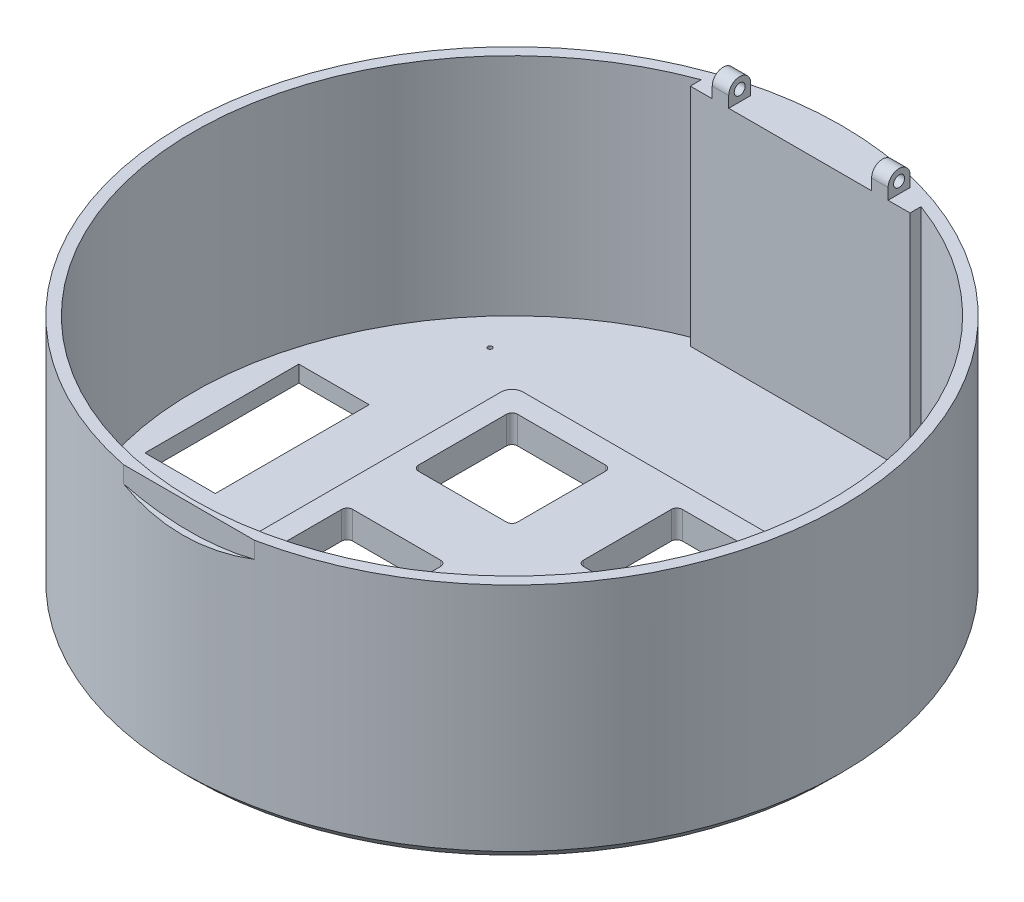
from build123d import *

# Parameters (mm, degrees)
SKETCH1_R                 = 15
BOSS_EXTRUDE1_DEPTH       = 11
SHELL1_T                  = -0.5
SHELL1_THICKNESS_2_FACE_R = 14.5
SHELL1_THICKNESS_2_DEPTH  = 0.25
CUT_EXTRUDE1_REACH        = 25.896
SKETCH2_R                 = 0.1
SKETCH2_W                 = 4.5
SKETCH2_H                 = 4.5
SKETCH2_W_2               = 3.2
SKETCH2_H_2               = 7
CHAMFER1_SIZE             = 0.5
FILLET1_R                 = 0.25
CUT_EXTRUDE2_START        = 15
CUT_EXTRUDE2_DEPTH        = 0.3
BOSS_EXTRUDE2_DEPTH       = 10.25
SKETCH7_W                 = 0.75
SKETCH7_H                 = 1
BOSS_EXTRUDE3_DEPTH       = 1
SKETCH8_R                 = 0.25
CUT_EXTRUDE3_DEPTH        = 28.018512298
BOSS_EXTRUDE5_DEPTH       = 0.5
MIRROR2_COPY_1_DEPTH      = 0.5
SCALE1_SCALE              = 10


with BuildPart() as part:
    # Sketch1 → Boss-Extrude1 (new body)
    with BuildSketch(Plane(origin=(0, 0, 0), x_dir=(1, 0, 0), z_dir=(0, 1, 0))):
        with Locations(Location((0, 0, 0), (0, 0, 270))):
            Circle(SKETCH1_R)
    extrude(amount=BOSS_EXTRUDE1_DEPTH)

    # Shell1
    shell1_openings = [part.faces().sort_by_distance(p)[0] for p in [
        (0, 11, 0),
    ]]
    offset(amount=SHELL1_T, openings=shell1_openings, kind=Kind.INTERSECTION)

    # Shell1 thickness 2 face (on inner face of the shell) → Shell1 thickness 2 (add)
    with BuildSketch(Plane(origin=(0, 0.5, 0), x_dir=(0, 0, -1), z_dir=(0, -1, 0))):
        Circle(SHELL1_THICKNESS_2_FACE_R)
    extrude(amount=-SHELL1_THICKNESS_2_DEPTH)

    # Sketch2 → Cut-Extrude1 (cut, up to next)
    with BuildSketch(Plane.XZ, mode=Mode.PRIVATE) as cut_extrude1_sk1:
        with Locations(Location((-9.5, 8.5, 0), (0, 0, 270))):
            Circle(SKETCH2_R)
    cut_extrude1_tool1 = extrude(cut_extrude1_sk1.sketch, amount=-CUT_EXTRUDE1_REACH, mode=Mode.PRIVATE) & part.part
    # Sketch2 → Cut-Extrude1 (cut, up to next)
    with BuildSketch(Plane.XZ, mode=Mode.PRIVATE) as cut_extrude1_sk2:
        with Locations(Location((-9.5, -8.5, 0), (0, 0, 90))):
            Circle(SKETCH2_R)
    cut_extrude1_tool2 = extrude(cut_extrude1_sk2.sketch, amount=-CUT_EXTRUDE1_REACH, mode=Mode.PRIVATE) & part.part
    # Sketch2 → Cut-Extrude1 (cut, up to next)
    with BuildSketch(Plane.XZ, mode=Mode.PRIVATE) as cut_extrude1_sk3:
        with Locations(Location((9.5, 8.5, 0), (0, 0, 90))):
            Circle(SKETCH2_R)
    cut_extrude1_tool3 = extrude(cut_extrude1_sk3.sketch, amount=-CUT_EXTRUDE1_REACH, mode=Mode.PRIVATE) & part.part
    # Sketch2 → Cut-Extrude1 (cut, up to next)
    with BuildSketch(Plane.XZ, mode=Mode.PRIVATE) as cut_extrude1_sk4:
        with Locations(Location((9.5, -8.5, 0), (0, 0, 270))):
            Circle(SKETCH2_R)
    cut_extrude1_tool4 = extrude(cut_extrude1_sk4.sketch, amount=-CUT_EXTRUDE1_REACH, mode=Mode.PRIVATE) & part.part
    # Sketch2 → Cut-Extrude1 (cut, up to next)
    with BuildSketch(Plane.XZ, mode=Mode.PRIVATE) as cut_extrude1_sk5:
        with Locations((-3.75, 3.75)):
            Rectangle(SKETCH2_W, SKETCH2_H)
    cut_extrude1_tool5 = extrude(cut_extrude1_sk5.sketch, amount=-CUT_EXTRUDE1_REACH, mode=Mode.PRIVATE) & part.part
    # Sketch2 → Cut-Extrude1 (cut, up to next)
    with BuildSketch(Plane.XZ, mode=Mode.PRIVATE) as cut_extrude1_sk6:
        with Locations((-3.75, -3.75)):
            Rectangle(SKETCH2_W, SKETCH2_H)
    cut_extrude1_tool6 = extrude(cut_extrude1_sk6.sketch, amount=-CUT_EXTRUDE1_REACH, mode=Mode.PRIVATE) & part.part
    # Sketch2 → Cut-Extrude1 (cut, up to next)
    with BuildSketch(Plane.XZ, mode=Mode.PRIVATE) as cut_extrude1_sk7:
        with Locations((11.6, 0)):
            Rectangle(SKETCH2_W_2, SKETCH2_H_2)
    cut_extrude1_tool7 = extrude(cut_extrude1_sk7.sketch, amount=-CUT_EXTRUDE1_REACH, mode=Mode.PRIVATE) & part.part
    # Sketch2 → Cut-Extrude1 (cut, up to next)
    with BuildSketch(Plane.XZ, mode=Mode.PRIVATE) as cut_extrude1_sk8:
        with Locations((-11.6, 0)):
            Rectangle(SKETCH2_W_2, SKETCH2_H_2)
    cut_extrude1_tool8 = extrude(cut_extrude1_sk8.sketch, amount=-CUT_EXTRUDE1_REACH, mode=Mode.PRIVATE) & part.part
    # Sketch2 → Cut-Extrude1 (cut, up to next)
    with BuildSketch(Plane.XZ, mode=Mode.PRIVATE) as cut_extrude1_sk9:
        with Locations((3.75, -3.75)):
            Rectangle(SKETCH2_W, SKETCH2_H)
    cut_extrude1_tool9 = extrude(cut_extrude1_sk9.sketch, amount=-CUT_EXTRUDE1_REACH, mode=Mode.PRIVATE) & part.part
    # Sketch2 → Cut-Extrude1 (cut, up to next)
    with BuildSketch(Plane.XZ, mode=Mode.PRIVATE) as cut_extrude1_sk10:
        with Locations((3.75, 3.75)):
            Rectangle(SKETCH2_W, SKETCH2_H)
    cut_extrude1_tool10 = extrude(cut_extrude1_sk10.sketch, amount=-CUT_EXTRUDE1_REACH, mode=Mode.PRIVATE) & part.part
    add(cut_extrude1_tool1.solids().sort_by_distance((-9.5, 0, 8.5))[0], mode=Mode.SUBTRACT)
    add(cut_extrude1_tool2.solids().sort_by_distance((-9.5, 0, -8.5))[0], mode=Mode.SUBTRACT)
    add(cut_extrude1_tool3.solids().sort_by_distance((9.5, 0, 8.5))[0], mode=Mode.SUBTRACT)
    add(cut_extrude1_tool4.solids().sort_by_distance((9.5, 0, -8.5))[0], mode=Mode.SUBTRACT)
    add(cut_extrude1_tool5.solids().sort_by_distance((-3.75, 0, 3.75))[0], mode=Mode.SUBTRACT)
    add(cut_extrude1_tool6.solids().sort_by_distance((-3.75, 0, -3.75))[0], mode=Mode.SUBTRACT)
    add(cut_extrude1_tool7.solids().sort_by_distance((11.6, 0, 0))[0], mode=Mode.SUBTRACT)
    add(cut_extrude1_tool8.solids().sort_by_distance((-11.6, 0, 0))[0], mode=Mode.SUBTRACT)
    add(cut_extrude1_tool9.solids().sort_by_distance((3.75, 0, -3.75))[0], mode=Mode.SUBTRACT)
    add(cut_extrude1_tool10.solids().sort_by_distance((3.75, 0, 3.75))[0], mode=Mode.SUBTRACT)

    # Chamfer1
    chamfer1_edges = [part.edges().sort_by_distance(p)[0] for p in [
        (0, 0, -15),
    ]]
    chamfer(chamfer1_edges, length=CHAMFER1_SIZE)

    # Fillet1
    fillet1_edges = [part.edges().sort_by_distance(p)[0] for p in [
        (-1.5, 0.375, -6),
        (-6, 0.375, -6),
        (-6, 0.375, -1.5),
        (-1.5, 0.375, -1.5),
        (6, 0.375, -1.5),
        (6, 0.375, -6),
        (1.5, 0.375, -6),
        (1.5, 0.375, -1.5),
        (1.5, 0.375, 6),
        (6, 0.375, 6),
        (6, 0.375, 1.5),
        (1.5, 0.375, 1.5),
        (-6, 0.375, 1.5),
        (-6, 0.375, 6),
        (-1.5, 0.375, 6),
        (-1.5, 0.375, 1.5),
    ]]
    fillet(fillet1_edges, radius=FILLET1_R)

    # Sketch4 → Cut-Extrude2 (cut)
    with BuildSketch(Plane.XY.offset(CUT_EXTRUDE2_START)):
        with BuildLine():
            Line((-3, 11), (3, 11))
            Line((3, 11), (3, 10.25))
            ThreePointArc((3, 10.25), (0, 9.868950039), (-3, 10.25))
            Line((-3, 10.25), (-3, 11))
        make_face()
    extrude(amount=-CUT_EXTRUDE2_DEPTH, mode=Mode.SUBTRACT)

    # Sketch5 → Boss-Extrude2 (add)
    with BuildSketch(Plane(origin=(0, 0.75, 0), x_dir=(1, 0, 0), z_dir=(0, 1, 0))):
        with BuildLine():
            Line((-5, 13.610657589), (-5, 13.110657589))
            Line((-5, 13.110657589), (5, 13.110657589))
            Line((5, 13.110657589), (5, 13.610657589))
            ThreePointArc((5, 13.610657589), (0, 14.5), (-5, 13.610657589))
        make_face()
    extrude(amount=BOSS_EXTRUDE2_DEPTH)

    # Sketch7 → Boss-Extrude3 (add)
    with BuildSketch(Plane(origin=(0, 11, 0), x_dir=(1, 0, 0), z_dir=(0, 1, 0))):
        with Locations((3.625, 13.610657589)):
            Rectangle(SKETCH7_W, SKETCH7_H)
        with Locations((-3.625, 13.610657589)):
            Rectangle(SKETCH7_W, SKETCH7_H)
    extrude(amount=BOSS_EXTRUDE3_DEPTH)

    # Sketch8 → Cut-Extrude3 (cut, through all)
    with BuildSketch(Plane(origin=(4, 0, 0), x_dir=(0, 0, -1), z_dir=(1, 0, 0))):
        with BuildLine():
            Line((13.110657589, 12), (13.110657589, 11.5))
            ThreePointArc((13.110657589, 11.5), (13.257104198, 11.853553391), (13.610657589, 12))
            Line((13.610657589, 12), (13.110657589, 12))
        make_face()
        with BuildLine():
            Line((14.110657589, 12), (13.610657589, 12))
            ThreePointArc((13.610657589, 12), (13.964210979, 11.853553391), (14.110657589, 11.5))
            Line((14.110657589, 11.5), (14.110657589, 12))
        make_face()
        with Locations((13.610657589, 11.5)):
            Circle(SKETCH8_R)
    extrude(amount=-CUT_EXTRUDE3_DEPTH, mode=Mode.SUBTRACT)

    # Sketch10 → Boss-Extrude5 (add)
    with BuildSketch(Plane(origin=(0, 0.75, 0), x_dir=(1, 0, 0), z_dir=(0, 1, 0))):
        with BuildLine():
            Line((-6.5, 7), (6.5, 7))
            ThreePointArc((6.5, 7), (6.853553391, 6.853553391), (7, 6.5))
            Line((7, 6.5), (7, -6.5))
            ThreePointArc((7, -6.5), (6.853553391, -6.853553391), (6.5, -7))
            Line((6.5, -7), (-6.5, -7))
            ThreePointArc((-6.5, -7), (-6.853553391, -6.853553391), (-7, -6.5))
            Line((-7, -6.5), (-7, 6.5))
            ThreePointArc((-7, 6.5), (-6.853553391, 6.853553391), (-6.5, 7))
        make_face()
        with BuildLine():
            Line((-1.5, -1.75), (-1.5, -5.75))
            ThreePointArc((-1.5, -5.75), (-1.573223305, -5.926776695), (-1.75, -6))
            Line((-1.75, -6), (-5.75, -6))
            ThreePointArc((-5.75, -6), (-5.926776695, -5.926776695), (-6, -5.75))
            Line((-6, -5.75), (-6, -1.75))
            ThreePointArc((-6, -1.75), (-5.926776695, -1.573223305), (-5.75, -1.5))
            Line((-5.75, -1.5), (-1.75, -1.5))
            ThreePointArc((-1.75, -1.5), (-1.573223305, -1.573223305), (-1.5, -1.75))
        make_face(mode=Mode.SUBTRACT)
        with BuildLine():
            Line((6, -1.75), (6, -5.75))
            ThreePointArc((6, -5.75), (5.926776695, -5.926776695), (5.75, -6))
            Line((5.75, -6), (1.75, -6))
            ThreePointArc((1.75, -6), (1.573223305, -5.926776695), (1.5, -5.75))
            Line((1.5, -5.75), (1.5, -1.75))
            ThreePointArc((1.5, -1.75), (1.573223305, -1.573223305), (1.75, -1.5))
            Line((1.75, -1.5), (5.75, -1.5))
            ThreePointArc((5.75, -1.5), (5.926776695, -1.573223305), (6, -1.75))
        make_face(mode=Mode.SUBTRACT)
        with BuildLine():
            Line((6, 5.75), (6, 1.75))
            ThreePointArc((6, 1.75), (5.926776695, 1.573223305), (5.75, 1.5))
            Line((5.75, 1.5), (1.75, 1.5))
            ThreePointArc((1.75, 1.5), (1.573223305, 1.573223305), (1.5, 1.75))
            Line((1.5, 1.75), (1.5, 5.75))
            ThreePointArc((1.5, 5.75), (1.573223305, 5.926776695), (1.75, 6))
            Line((1.75, 6), (5.75, 6))
            ThreePointArc((5.75, 6), (5.926776695, 5.926776695), (6, 5.75))
        make_face(mode=Mode.SUBTRACT)
        with BuildLine():
            Line((-1.5, 5.75), (-1.5, 1.75))
            ThreePointArc((-1.5, 1.75), (-1.573223305, 1.573223305), (-1.75, 1.5))
            Line((-1.75, 1.5), (-5.75, 1.5))
            ThreePointArc((-5.75, 1.5), (-5.926776695, 1.573223305), (-6, 1.75))
            Line((-6, 1.75), (-6, 5.75))
            ThreePointArc((-6, 5.75), (-5.926776695, 5.926776695), (-5.75, 6))
            Line((-5.75, 6), (-1.75, 6))
            ThreePointArc((-1.75, 6), (-1.573223305, 5.926776695), (-1.5, 5.75))
        make_face(mode=Mode.SUBTRACT)
    boss_extrude5 = extrude(amount=BOSS_EXTRUDE5_DEPTH)

    # Mirror1: Boss-Extrude5 across plane
    add(boss_extrude5.mirror(Plane(origin=(0, 0, 0), x_dir=(0, 0, 1), z_dir=(1, 0, 0))))

    # Mirror2: Boss-Extrude5 across plane
    add(boss_extrude5.mirror(Plane.XY))

    # Mirror2 copy 1 sketch → Mirror2 copy 1 (add)
    with BuildSketch(Plane(origin=(0, 0.75, 0), x_dir=(-1, 0, 0), z_dir=(0, 1, 0))):
        with BuildLine():
            Line((-6.5, 7), (6.5, 7))
            ThreePointArc((6.5, 7), (6.853553391, 6.853553391), (7, 6.5))
            Line((7, 6.5), (7, -6.5))
            ThreePointArc((7, -6.5), (6.853553391, -6.853553391), (6.5, -7))
            Line((6.5, -7), (-6.5, -7))
            ThreePointArc((-6.5, -7), (-6.853553391, -6.853553391), (-7, -6.5))
            Line((-7, -6.5), (-7, 6.5))
            ThreePointArc((-7, 6.5), (-6.853553391, 6.853553391), (-6.5, 7))
        make_face()
        with BuildLine():
            Line((-1.5, -1.75), (-1.5, -5.75))
            ThreePointArc((-1.5, -5.75), (-1.573223305, -5.926776695), (-1.75, -6))
            Line((-1.75, -6), (-5.75, -6))
            ThreePointArc((-5.75, -6), (-5.926776695, -5.926776695), (-6, -5.75))
            Line((-6, -5.75), (-6, -1.75))
            ThreePointArc((-6, -1.75), (-5.926776695, -1.573223305), (-5.75, -1.5))
            Line((-5.75, -1.5), (-1.75, -1.5))
            ThreePointArc((-1.75, -1.5), (-1.573223305, -1.573223305), (-1.5, -1.75))
        make_face(mode=Mode.SUBTRACT)
        with BuildLine():
            Line((6, -1.75), (6, -5.75))
            ThreePointArc((6, -5.75), (5.926776695, -5.926776695), (5.75, -6))
            Line((5.75, -6), (1.75, -6))
            ThreePointArc((1.75, -6), (1.573223305, -5.926776695), (1.5, -5.75))
            Line((1.5, -5.75), (1.5, -1.75))
            ThreePointArc((1.5, -1.75), (1.573223305, -1.573223305), (1.75, -1.5))
            Line((1.75, -1.5), (5.75, -1.5))
            ThreePointArc((5.75, -1.5), (5.926776695, -1.573223305), (6, -1.75))
        make_face(mode=Mode.SUBTRACT)
        with BuildLine():
            Line((6, 5.75), (6, 1.75))
            ThreePointArc((6, 1.75), (5.926776695, 1.573223305), (5.75, 1.5))
            Line((5.75, 1.5), (1.75, 1.5))
            ThreePointArc((1.75, 1.5), (1.573223305, 1.573223305), (1.5, 1.75))
            Line((1.5, 1.75), (1.5, 5.75))
            ThreePointArc((1.5, 5.75), (1.573223305, 5.926776695), (1.75, 6))
            Line((1.75, 6), (5.75, 6))
            ThreePointArc((5.75, 6), (5.926776695, 5.926776695), (6, 5.75))
        make_face(mode=Mode.SUBTRACT)
        with BuildLine():
            Line((-1.5, 5.75), (-1.5, 1.75))
            ThreePointArc((-1.5, 1.75), (-1.573223305, 1.573223305), (-1.75, 1.5))
            Line((-1.75, 1.5), (-5.75, 1.5))
            ThreePointArc((-5.75, 1.5), (-5.926776695, 1.573223305), (-6, 1.75))
            Line((-6, 1.75), (-6, 5.75))
            ThreePointArc((-6, 5.75), (-5.926776695, 5.926776695), (-5.75, 6))
            Line((-5.75, 6), (-1.75, 6))
            ThreePointArc((-1.75, 6), (-1.573223305, 5.926776695), (-1.5, 5.75))
        make_face(mode=Mode.SUBTRACT)
    extrude(amount=MIRROR2_COPY_1_DEPTH)


with BuildPart() as part_1:
    # Scale1: scaled about (0, 3.432185883, -1.470574169)
    add(part.part.scale(SCALE1_SCALE).moved(Location((0, -30.889672947, 13.235167521))))


solid = part_1.part
